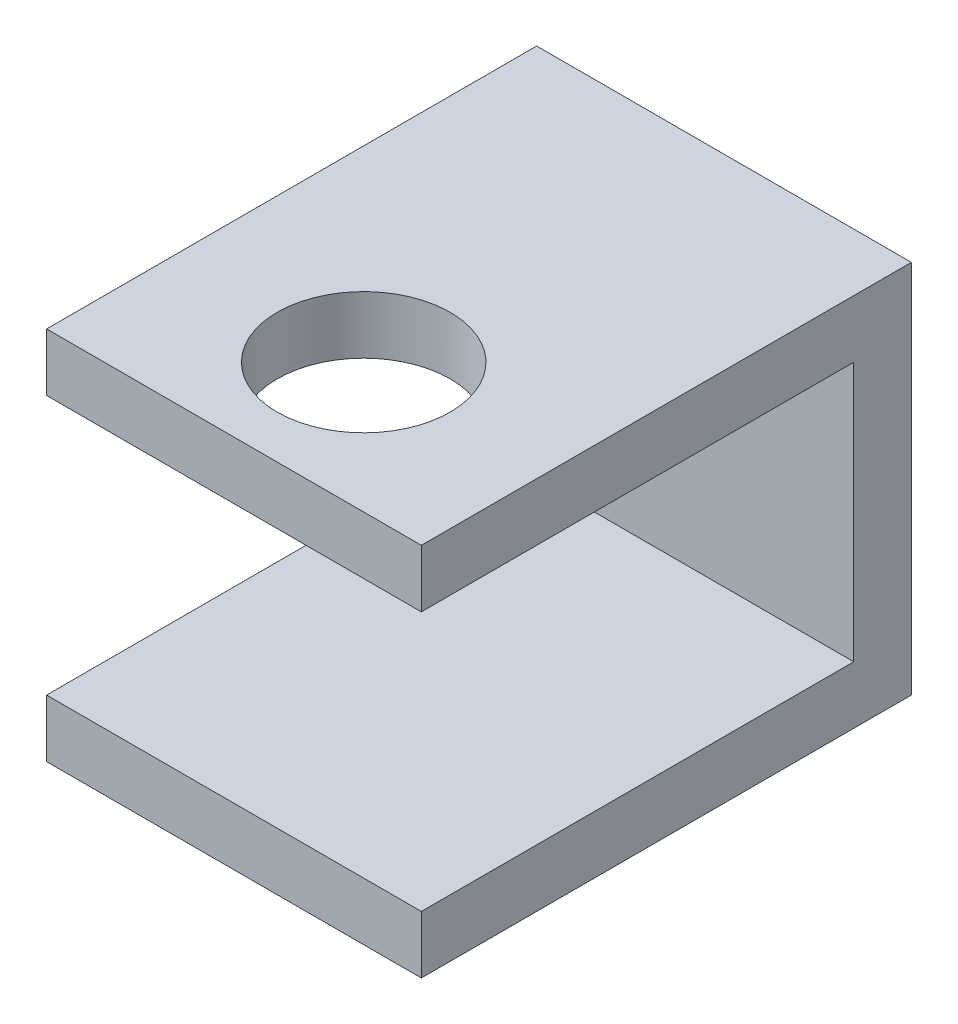
from build123d import *

# Parameters (mm, degrees)
SKETCH2_W           = 1.3
SKETCH2_H           = 1.3
BOSS_EXTRUDE2_DEPTH = 1.7
SKETCH10_W          = 1.3
SKETCH10_H          = 0.9
CUT_EXTRUDE4_DEPTH  = 2
SKETCH12_R          = 0.3
CUT_EXTRUDE5_DEPTH  = 1.3
SKETCH14_W          = 1.3
SKETCH14_H          = 1.3
BOSS_EXTRUDE3_DEPTH = 0.2


with BuildPart() as part:
    # Sketch2 → Boss-Extrude2 (new body)
    with BuildSketch(Plane.XY):
        with Locations((0.65, 0.65)):
            Rectangle(SKETCH2_W, SKETCH2_H)
    extrude(amount=BOSS_EXTRUDE2_DEPTH)

    # Sketch10 → Cut-Extrude4 (cut)
    with BuildSketch(Plane.XY.offset(1.7)):
        with Locations((0.65, 0.65)):
            Rectangle(SKETCH10_W, SKETCH10_H)
    extrude(amount=-CUT_EXTRUDE4_DEPTH, mode=Mode.SUBTRACT)


with BuildPart() as cut_extrude4_piece_1:
    # of the separate pieces the step leaves, piece 1, a body of its own (cut_extrude4_pieces)
    add(part.part.solids().sort_by_distance((0, 1.3, 0))[0])

    # Sketch12 → Cut-Extrude5 (cut)
    with BuildSketch(Plane(origin=(0, 1.3, 0), x_dir=(1, 0, 0), z_dir=(0, 1, 0))):
        with Locations(Location((0.65, -1.25, 0), (0, 0, 270))):
            Circle(SKETCH12_R)
    extrude(amount=-CUT_EXTRUDE5_DEPTH, mode=Mode.SUBTRACT)



with BuildPart() as cut_extrude4_piece_2:
    # of the separate pieces the step leaves, piece 2, a body of its own (cut_extrude4_pieces)
    add(part.part.solids().sort_by_distance((0, 0, 0))[0])


with BuildPart() as cut_extrude4_piece_1_1:
    add(cut_extrude4_piece_1.part)

    add(cut_extrude4_piece_2.part)  # Boss-Extrude3 merges Cut-Extrude4 piece 2
    # Sketch14 → Boss-Extrude3 (add)
    with BuildSketch(Plane(origin=(0, 0, 0), x_dir=(-1, 0, 0), z_dir=(0, 0, -1))):
        with Locations((-0.65, 0.65)):
            Rectangle(SKETCH14_W, SKETCH14_H)
    extrude(amount=-BOSS_EXTRUDE3_DEPTH)


solid = cut_extrude4_piece_1_1.part
